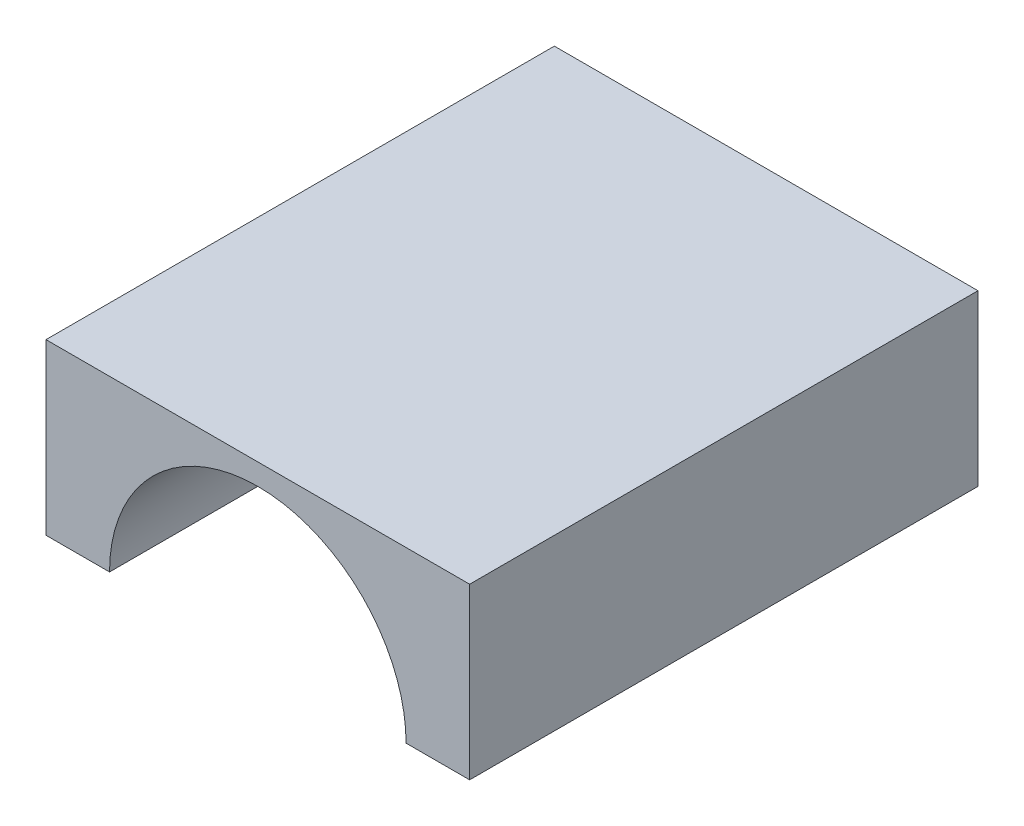
from build123d import *

# Parameters (mm, degrees)
SKETCH1_W           = 20
SKETCH1_H           = 24
BOSS_EXTRUDE1_DEPTH = 8
SKETCH2_R           = 7
CUT_EXTRUDE1_DEPTH  = 22
BOSS_EXTRUDE2_DEPTH = 2


with BuildPart() as part:
    # Sketch1 → Boss-Extrude1 (new body)
    with BuildSketch(Plane(origin=(0, 0, 0), x_dir=(1, 0, 0), z_dir=(0, 1, 0))):
        Rectangle(SKETCH1_W, SKETCH1_H)
    extrude(amount=BOSS_EXTRUDE1_DEPTH)

    # Sketch2 → Cut-Extrude1 (cut)
    with BuildSketch(Plane.XY.offset(12)):
        Circle(SKETCH2_R)
    extrude(amount=-CUT_EXTRUDE1_DEPTH, mode=Mode.SUBTRACT)

    # Sketch3 → Boss-Extrude2 (add)
    with BuildSketch(Plane(origin=(0, 0, -12), x_dir=(-1, 0, 0), z_dir=(0, 0, -1))):
        with BuildLine():
            Line((-2, -6.708203932), (-2, -5))
            Line((-2, -5), (2, -5))
            Line((2, -5), (2, -6.708203932))
            ThreePointArc((2, -6.708203932), (0, 7), (-2, -6.708203932))
        make_face()
    extrude(amount=-BOSS_EXTRUDE2_DEPTH)


solid = part.part
